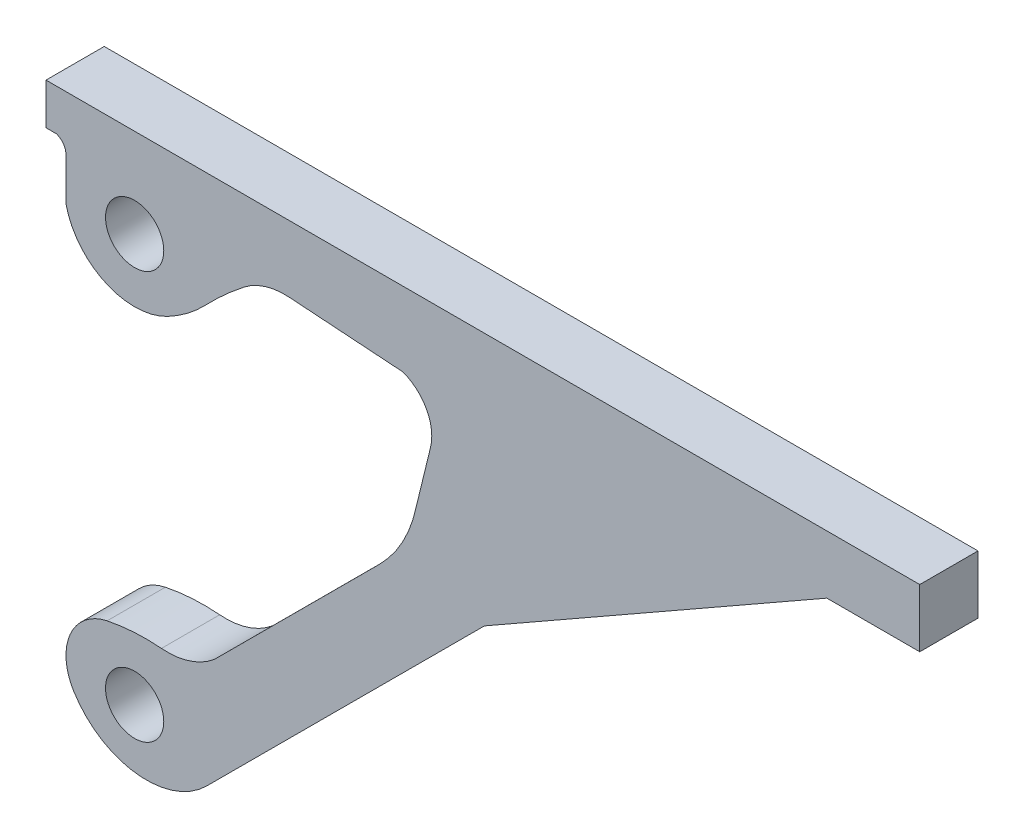
from build123d import *

# Parameters (mm, degrees)
SZKIC2_R                    = 10
DODANIE_WYCI_GNI_CIE2_DEPTH = 20


with BuildPart() as part:
    # Szkic2 → Dodanie-wyciągnięcie2 (new body)
    with BuildSketch(Plane.XY):
        with BuildLine():
            Line((0, 185.8153975), (0, 200))
            Line((0, 200), (300, 200))
            Line((300, 200), (300, 179.99999))
            Line((300, 179.99999), (268.100984266, 179.99999))
            Line((268.100984266, 179.99999), (150.537685313, 112.968737031))
            Line((150.537685313, 112.968737031), (55.152827757, 17.668229265))
            ThreePointArc((55.152827757, 17.668229265), (30.970417819, 9.307465427), (9.446642737, 23.142870322))
            ThreePointArc((9.446642737, 23.142870322), (8.323346954, 39.404883236), (20.969056487, 49.690839091))
            ThreePointArc((20.969056487, 49.690839091), (30.26105361, 50.929938535), (39.634727212, 50.825913662))
            ThreePointArc((39.634727212, 50.825913662), (49.37359719, 51.953421869), (57.922039747, 56.753525311))
            Line((57.922039747, 56.753525311), (114.485527726, 113.266993629))
            ThreePointArc((114.485527726, 113.266993629), (122.461819258, 123.951300931), (127.060971476, 136.466229937))
            Line((127.060971476, 136.466229937), (132.025285125, 156.762570766))
            ThreePointArc((132.025285125, 156.762570766), (130.65411111, 167.466839441), (122.461819258, 174.491641238))
            Line((122.461819258, 174.491641238), (83.453647812, 177.186358886))
            ThreePointArc((83.453647812, 177.186358886), (75.274757646, 176.24414951), (67.979862212, 172.427540613))
            ThreePointArc((67.979862212, 172.427540613), (61.096304048, 166.616485937), (54.641338034, 160.332765448))
            ThreePointArc((54.641338034, 160.332765448), (48.563505303, 154.928947374), (41.697006274, 150.570909792))
            ThreePointArc((41.697006274, 150.570909792), (20.320793886, 150.001184012), (6.859784063, 166.616485937))
            Line((6.859784063, 166.616485937), (6.859784063, 181.256700403))
            ThreePointArc((6.859784063, 181.256700403), (5.949401229, 184.069477829), (3.56355164, 185.8153975))
            Line((3.56355164, 185.8153975), (0, 185.8153975))
        make_face()
        with Locations((30.431430438, 29.443458524)):
            Circle(SZKIC2_R, mode=Mode.SUBTRACT)
        with Locations((30.431430438, 169.443458524)):
            Circle(SZKIC2_R, mode=Mode.SUBTRACT)
    extrude(amount=DODANIE_WYCI_GNI_CIE2_DEPTH)


solid = part.part
